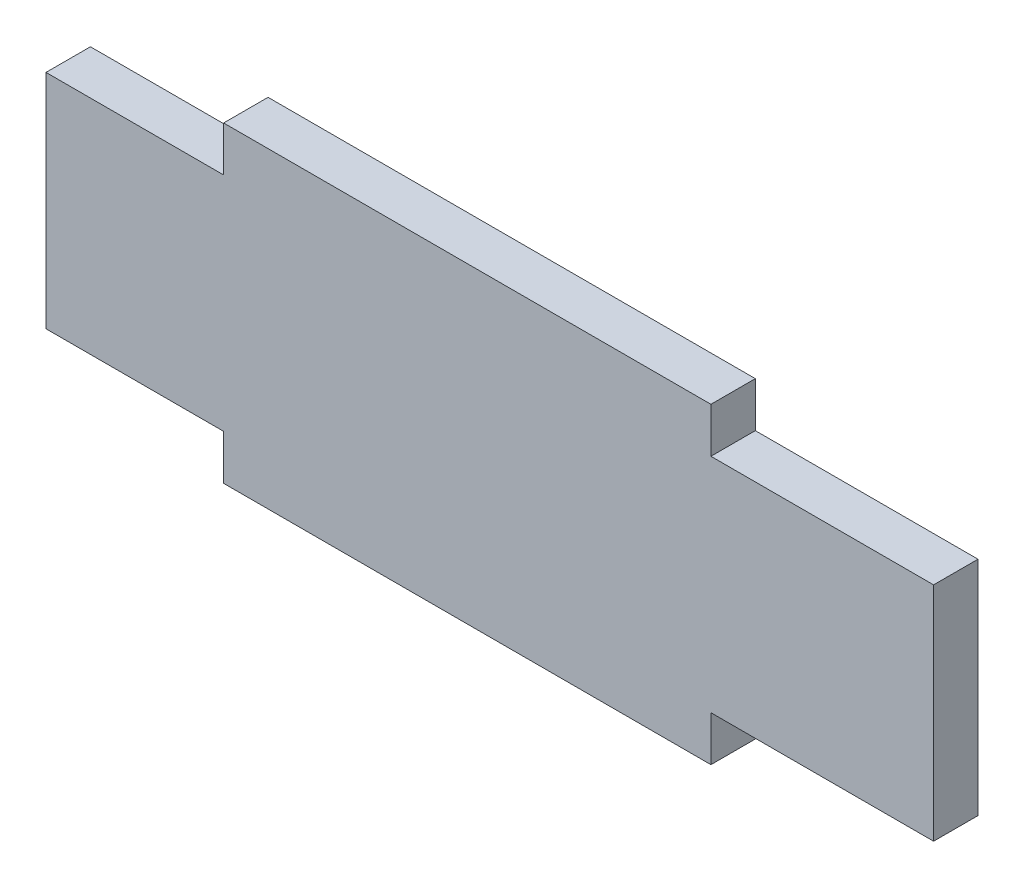
from build123d import *

# Parameters (mm, degrees)
SKETCH_1_W      = 99.93
SKETCH_1_H      = 25
SKETCH_1_W_2    = 54.86
SKETCH_1_H_2    = 5.07
EXTRUDE_1_DEPTH = 5


with BuildPart() as part:
    # ｽｹｯﾁ1 → ﾎﾞｽ - 押し出し1 (new body)
    with BuildSketch(Plane.XY):
        with Locations((49.965, 12.5)):
            Rectangle(SKETCH_1_W, SKETCH_1_H)
        with Locations((47.43, 27.535)):
            Rectangle(SKETCH_1_W_2, SKETCH_1_H_2)
        with Locations((47.43, -2.535)):
            Rectangle(SKETCH_1_W_2, SKETCH_1_H_2)
    extrude(amount=EXTRUDE_1_DEPTH)


solid = part.part
